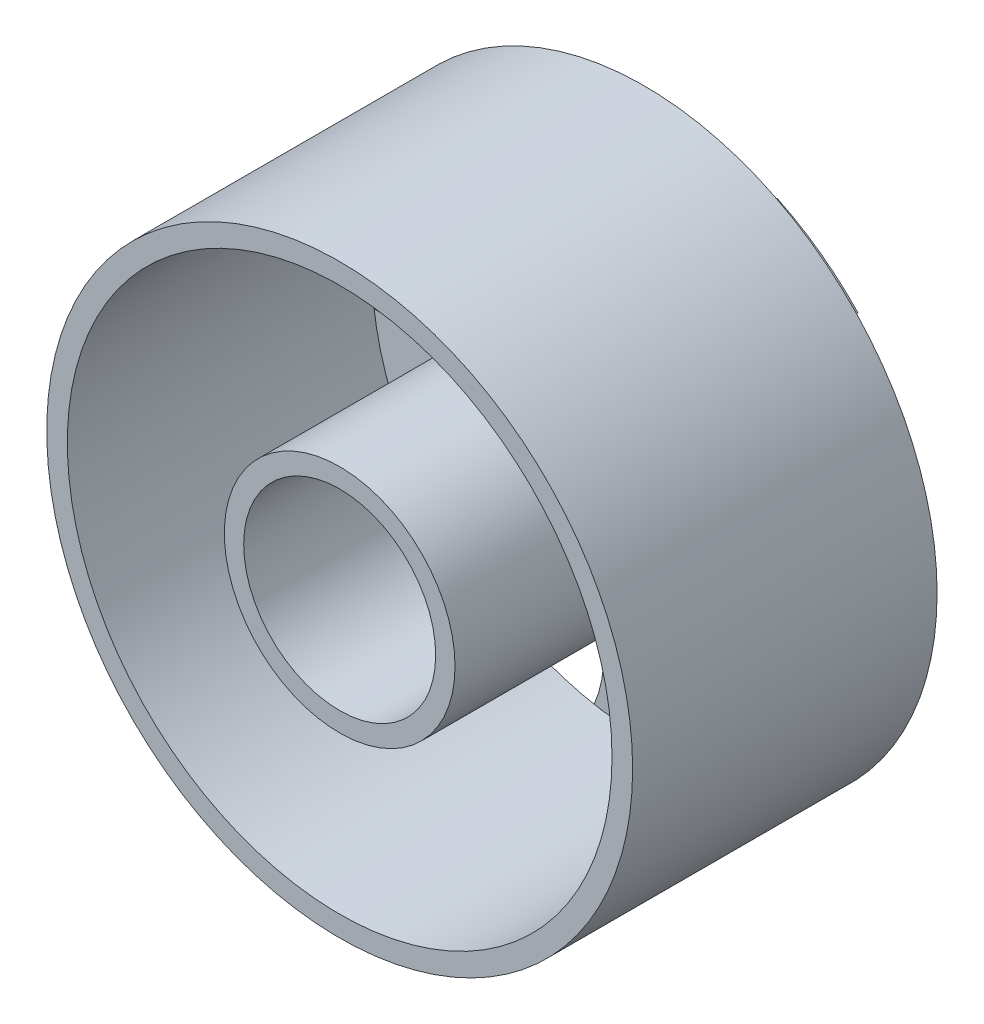
from build123d import *

# Parameters (mm, degrees)
SKETCH1_R             = 13.931034295
SKETCH1_R_2           = 12.951126788
BOSS_EXTRUDE1_DEPTH   = 14.478
SKETCH1_R_3           = 5.48525759
SKETCH1_R_4           = 4.565095147
BOSS_EXTRUDE1_2_DEPTH = 14.478
SKETCH2_R             = 12.951126788
BOSS_EXTRUDE2_DEPTH   = 0.762
SKETCH4_R             = 5.699074366
CUT_EXTRUDE2_DEPTH    = 0.762
CIRPATTERN2_COUNT     = 5
SKETCH6_R             = 4.565095147
CUT_EXTRUDE3_DEPTH    = 0.762


with BuildPart() as part:
    # Sketch1 → Boss-Extrude1 (new body)
    with BuildSketch(Plane.XY):
        Circle(SKETCH1_R)
        Circle(SKETCH1_R_2, mode=Mode.SUBTRACT)
    extrude(amount=BOSS_EXTRUDE1_DEPTH)


with BuildPart() as body_2:
    # Sketch1 → Boss-Extrude1 2 (new body)
    with BuildSketch(Plane.XY):
        Circle(SKETCH1_R_3)
        Circle(SKETCH1_R_4, mode=Mode.SUBTRACT)
    extrude(amount=BOSS_EXTRUDE1_2_DEPTH)

    # Sketch2 → Boss-Extrude2 (add)
    with BuildSketch(Plane(origin=(0, 0, 0), x_dir=(-1, 0, 0), z_dir=(0, 0, -1))):
        Circle(SKETCH2_R)
    extrude(amount=BOSS_EXTRUDE2_DEPTH)

    # Sketch4 → Cut-Extrude2 (cut)
    with BuildSketch(Plane(origin=(0, 0, -0.762), x_dir=(-1, 0, 0), z_dir=(0, 0, -1))):
        with Locations((0, 12.951126788)):
            Circle(SKETCH4_R)
    cut_extrude2 = extrude(amount=-CUT_EXTRUDE2_DEPTH, mode=Mode.SUBTRACT)

    # CirPattern2: Cut-Extrude2 ×5 about axis
    cirpattern2_axis = Axis((0, 0, 0), (0, 0, 1))
    for i in range(1, CIRPATTERN2_COUNT):
        add(cut_extrude2.rotate(cirpattern2_axis, i * 360 / CIRPATTERN2_COUNT), mode=Mode.SUBTRACT)

    # Sketch6 → Cut-Extrude3 (cut)
    with BuildSketch(Plane.XY):
        Circle(SKETCH6_R)
    extrude(amount=-CUT_EXTRUDE3_DEPTH, mode=Mode.SUBTRACT)


solid = Compound([part.part, body_2.part])
